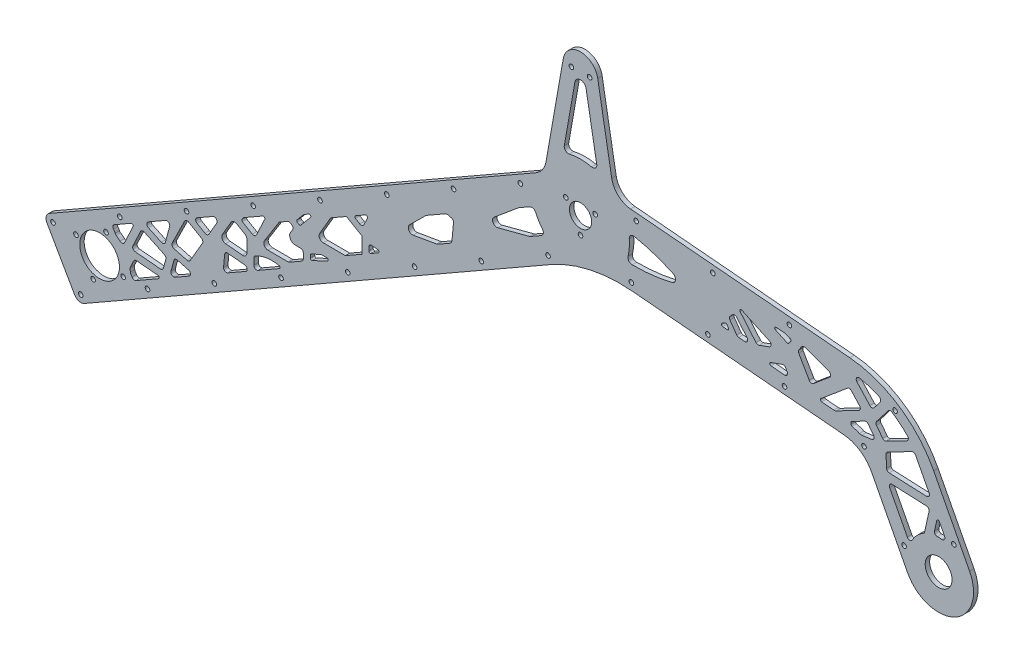
from build123d import *

# Parameters (mm, degrees)
SKETCH2_R              = 7.9375
SKETCH2_R_2            = 14.2
SKETCH2_R_3            = 1.65
SKETCH2_R_4            = 9.5885
BASE_DEPTH             = 3.175
SKETCH3_R              = 1.65
STRUT_HOLES_DEPTH      = 4.175
LIGHTENING_HOLES_DEPTH = 4.175
SKETCH7_R              = 1.65
CUT_EXTRUDE1_DEPTH     = 4.175


with BuildPart() as part:
    # Sketch2 → Base (new body)
    with BuildSketch(Plane.XY):
        with BuildLine():
            Line((-379.716809958, -188.506893436), (-32.006532147, 10.487277971))
            ThreePointArc((-32.006532147, 10.487277971), (-27.186230121, 14.879084252), (-24.685038782, 20.901319377))
            Line((-24.685038782, 20.901319377), (-12.310096913, 91.083102221))
            ThreePointArc((-12.310096913, 91.083102221), (0, 101.4125), (12.310096913, 91.083102221))
            Line((12.310096913, 91.083102221), (22.322003955, 34.302755831))
            ThreePointArc((22.322003955, 34.302755831), (26.960267136, 25.848318444), (35.786784109, 21.964558025))
            Line((35.786784109, 21.964558025), (192.586144941, 8.246391504))
            ThreePointArc((192.586144941, 8.246391504), (227.717231711, -4.10798993), (252.575276723, -31.83706486))
            Line((252.575276723, -31.83706486), (278.255270829, -81.167874559))
            ThreePointArc((278.255270829, -81.167874559), (267.623715331, -114.886860719), (233.904729171, -104.255305221))
            Line((233.904729171, -104.255305221), (208.224735064, -54.924495522))
            ThreePointArc((208.224735064, -54.924495522), (199.93872006, -45.681470545), (188.228357804, -41.563343401))
            Line((188.228357804, -41.563343401), (36.823729736, -28.317154839))
            ThreePointArc((36.823729736, -28.317154839), (6.649577682, -30.266109959), (-21.562664076, -41.144864173))
            Line((-21.562664076, -41.144864173), (-354.881400189, -231.902773674))
            ThreePointArc((-354.881400189, -231.902773674), (-358.677364619, -232.387866435), (-361.70452919, -230.046726627))
            Line((-361.70452919, -230.046726627), (-381.572857005, -195.330022437))
            ThreePointArc((-381.572857005, -195.330022437), (-382.057949767, -191.534058007), (-379.716809958, -188.506893436))
        make_face()
        Circle(SKETCH2_R, mode=Mode.SUBTRACT)
        with Locations((-343.92, -196.825)):
            Circle(SKETCH2_R_2, mode=Mode.SUBTRACT)
        with Locations((-6.5, 88.9125)):
            Circle(SKETCH2_R_3, mode=Mode.SUBTRACT)
        with Locations((6.5, 88.9125)):
            Circle(SKETCH2_R_3, mode=Mode.SUBTRACT)
        with Locations((256.08, -92.71158989)):
            Circle(SKETCH2_R_4, mode=Mode.SUBTRACT)
        with Locations((-360.806382749, -192.231517914)):
            Circle(SKETCH2_R_3, mode=Mode.SUBTRACT)
        with Locations((-339.326517914, -179.938617251)):
            Circle(SKETCH2_R_3, mode=Mode.SUBTRACT)
        with Locations((-327.033617251, -201.418482086)):
            Circle(SKETCH2_R_3, mode=Mode.SUBTRACT)
        with Locations((-348.513482086, -213.711382749)):
            Circle(SKETCH2_R_3, mode=Mode.SUBTRACT)
    extrude(amount=BASE_DEPTH)

    # Sketch3 → Strut Holes (cut, through all)
    with BuildSketch(Plane.XY.offset(3.175)):
        with Locations((-357.364941166, -227.56318565)):
            Circle(SKETCH3_R)
        with Locations((-309.629472905, -200.244234904)):
            Circle(SKETCH3_R)
        with Locations((-261.894004643, -172.925284158)):
            Circle(SKETCH3_R)
        with Locations((-214.158536382, -145.606333412)):
            Circle(SKETCH3_R)
        with Locations((-166.42306812, -118.287382666)):
            Circle(SKETCH3_R)
        with Locations((-118.687599859, -90.96843192)):
            Circle(SKETCH3_R)
        with Locations((-329.49780072, -165.527530714)):
            Circle(SKETCH3_R)
        with Locations((-377.233268981, -192.84648146)):
            Circle(SKETCH3_R)
        with Locations((-281.762332458, -138.208579968)):
            Circle(SKETCH3_R)
        with Locations((-234.026864197, -110.889629222)):
            Circle(SKETCH3_R)
        with Locations((-186.291395936, -83.570678476)):
            Circle(SKETCH3_R)
        with Locations((-138.555927674, -56.25172773)):
            Circle(SKETCH3_R)
        with Locations((36.307361546, -23.252879289)):
            Circle(SKETCH3_R)
        with Locations((91.098069941, -28.04644514)):
            Circle(SKETCH3_R)
        with Locations((145.888778336, -32.840010991)):
            Circle(SKETCH3_R)
        with Locations((149.375008046, 7.007776933)):
            Circle(SKETCH3_R)
        with Locations((94.584299651, 11.801342784)):
            Circle(SKETCH3_R)
        with Locations((39.793591256, 16.594908635)):
            Circle(SKETCH3_R)
        with Locations((-70.952131597, -63.649481174)):
            Circle(SKETCH3_R)
        with Locations((-23.216663336, -36.330530428)):
            Circle(SKETCH3_R)
        with Locations((-43.084991151, -1.613826238)):
            Circle(SKETCH3_R)
        with Locations((-90.820459413, -28.932776984)):
            Circle(SKETCH3_R)
        with Locations((202.716571226, -41.524122484)):
            Circle(SKETCH3_R)
        with Locations((224.939380546, -8.265337992)):
            Circle(SKETCH3_R)
        with Locations((231.413554138, -88.641399657)):
            Circle(SKETCH3_R)
        with Locations((266.893987465, -70.171455127)):
            Circle(SKETCH3_R)
    extrude(amount=-STRUT_HOLES_DEPTH, mode=Mode.SUBTRACT)

    # Sketch6 → Lightening Holes (cut, through all)
    with BuildSketch(Plane.XY.offset(3.175)):
        with BuildLine():
            Line((-317.937082153, -199.237754107), (-301.759255291, -189.979203363))
            ThreePointArc((-301.759255291, -189.979203363), (-301.27885272, -188.89855459), (-302.165025934, -188.115429161))
            Line((-302.165025934, -188.115429161), (-317.529091672, -186.71244549))
            ThreePointArc((-317.529091672, -186.71244549), (-318.704383169, -186.968323474), (-319.520360019, -187.852045956))
            Line((-319.520360019, -187.852045956), (-321.920665487, -192.94890269))
            ThreePointArc((-321.920665487, -192.94890269), (-322.086706026, -193.488507205), (-322.095332893, -194.053014132))
            ThreePointArc((-322.095332893, -194.053014132), (-321.995430567, -195.004765075), (-321.937013257, -195.959960211))
            ThreePointArc((-321.937013257, -195.959960211), (-321.816611469, -196.56901374), (-321.515239324, -197.111800643))
            ThreePointArc((-321.515239324, -197.111800643), (-321.089709213, -197.721191561), (-320.73119159, -198.372266273))
            ThreePointArc((-320.73119159, -198.372266273), (-319.522268091, -199.412366176), (-317.937082153, -199.237754107))
        make_face()
        with BuildLine():
            Line((-289.844978396, -183.160677107), (-279.93882887, -177.491399715))
            ThreePointArc((-279.93882887, -177.491399715), (-278.948378644, -175.502042811), (-280.407275879, -173.825692191))
            Line((-280.407275879, -173.825692191), (-288.292322007, -171.680779414))
            ThreePointArc((-288.292322007, -171.680779414), (-289.810707779, -171.874816518), (-290.747163702, -173.085682346))
            Line((-290.747163702, -173.085682346), (-292.868560549, -180.884280112))
            ThreePointArc((-292.868560549, -180.884280112), (-292.613471256, -182.502456625), (-291.234784363, -183.387209827))
            ThreePointArc((-291.234784363, -183.387209827), (-291.195764259, -183.393163574), (-291.156778347, -183.399337252))
            ThreePointArc((-291.156778347, -183.399337252), (-290.480404568, -183.392541824), (-289.844978396, -183.160677107))
        make_face()
        with BuildLine():
            Line((-225.068253149, -146.0890356), (-215.394271166, -140.552627413))
            ThreePointArc((-215.394271166, -140.552627413), (-214.903636001, -139.526112554), (-215.691072999, -138.704894803))
            ThreePointArc((-215.691072999, -138.704894803), (-224.321295756, -138.46558821), (-232.518295989, -141.176160044))
            ThreePointArc((-232.518295989, -141.176160044), (-233.286477009, -141.90836482), (-233.571916458, -142.930495063))
            Line((-233.571916458, -142.930495063), (-233.587977081, -147.160409637))
            Line((-233.587977081, -147.160409637), (-233.589300921, -147.509071621))
            ThreePointArc((-233.589300921, -147.509071621), (-232.59588453, -149.244906831), (-230.595898947, -149.252500605))
            Line((-230.595898947, -149.252500605), (-225.068253149, -146.0890356))
        make_face()
        with BuildLine():
            Line((-202.450189496, -105.529322903), (-201.311100417, -106.192755657))
            ThreePointArc((-201.311100417, -106.192755657), (-200.637908098, -106.314094916), (-200.044217491, -105.974326499))
            Line((-200.044217491, -105.974326499), (-193.10874934, -97.772404377))
            ThreePointArc((-193.10874934, -97.772404377), (-193.103868157, -96.486838424), (-194.369055865, -96.258795212))
            Line((-194.369055865, -96.258795212), (-197.510306407, -98.056529098))
            ThreePointArc((-197.510306407, -98.056529098), (-197.796638801, -98.255405281), (-198.044086675, -98.500981186))
            Line((-198.044086675, -98.500981186), (-202.710503229, -104.019510625))
            ThreePointArc((-202.710503229, -104.019510625), (-202.932364876, -104.835109908), (-202.450189496, -105.529322903))
        make_face()
        with BuildLine():
            Line((-333.444620565, -172.395023354), (-321.324736547, -165.45882839))
            ThreePointArc((-321.324736547, -165.45882839), (-320.149643655, -165.592039112), (-319.923331731, -166.752802359))
            Line((-319.923331731, -166.752802359), (-326.076688787, -179.818964042))
            ThreePointArc((-326.076688787, -179.818964042), (-327.489682534, -180.927174615), (-329.222241859, -180.455030372))
            ThreePointArc((-329.222241859, -180.455030372), (-330.587096563, -179.325466122), (-332.03841525, -178.309386485))
            ThreePointArc((-332.03841525, -178.309386485), (-332.502552417, -177.897052298), (-332.817881567, -177.362252973))
            ThreePointArc((-332.817881567, -177.362252973), (-333.319567754, -176.344657072), (-333.979051672, -175.421471605))
            ThreePointArc((-333.979051672, -175.421471605), (-334.420732076, -173.783065742), (-333.444620565, -172.395023354))
        make_face()
        with BuildLine():
            Line((-296.526078791, -175.281178461), (-298.296173769, -181.788333758))
            ThreePointArc((-298.296173769, -181.788333758), (-299.085121934, -182.906012266), (-300.407921189, -183.255077571))
            Line((-300.407921189, -183.255077571), (-318.426512518, -181.609693475))
            ThreePointArc((-318.426512518, -181.609693475), (-319.980472622, -180.611396672), (-320.054030653, -178.765867554))
            Line((-320.054030653, -178.765867554), (-314.587930437, -167.159040818))
            ThreePointArc((-314.587930437, -167.159040818), (-313.455436739, -166.129184627), (-311.926424469, -166.201760304))
            Line((-311.926424469, -166.201760304), (-297.603838378, -172.946815839))
            ThreePointArc((-297.603838378, -172.946815839), (-296.64013933, -173.917860945), (-296.526078791, -175.281178461))
        make_face()
        with BuildLine():
            Line((-296.725202345, -151.380544722), (-309.162121937, -158.49817876))
            ThreePointArc((-309.162121937, -158.49817876), (-310.167118822, -160.31366557), (-309.020818273, -162.043407211))
            Line((-309.020818273, -162.043407211), (-299.712508239, -166.427047688))
            ThreePointArc((-299.712508239, -166.427047688), (-298.022047377, -166.433466223), (-296.930523197, -165.142623828))
            Line((-296.930523197, -165.142623828), (-293.80191364, -153.641349312))
            ThreePointArc((-293.80191364, -153.641349312), (-294.508247327, -151.534307484), (-296.725202345, -151.380544722))
        make_face()
        with BuildLine():
            Line((-290.749203903, -165.830761417), (-281.418682259, -168.368876575))
            ThreePointArc((-281.418682259, -168.368876575), (-280.135367262, -168.289656018), (-279.165471442, -167.445573454))
            Line((-279.165471442, -167.445573454), (-270.334962051, -152.283921043))
            ThreePointArc((-270.334962051, -152.283921043), (-270.129400346, -150.767052513), (-271.056634293, -149.549110414))
            Line((-271.056634293, -149.549110414), (-280.339031078, -144.142820271))
            ThreePointArc((-280.339031078, -144.142820271), (-281.923077504, -143.956245777), (-283.139846515, -144.987500494))
            Line((-283.139846515, -144.987500494), (-292.018480766, -163.01732789))
            ThreePointArc((-292.018480766, -163.01732789), (-292.047293032, -164.72335957), (-290.749203903, -165.830761417))
        make_face()
        with BuildLine():
            Line((-274.174863713, -138.475013199), (-262.829621171, -131.982144615))
            ThreePointArc((-262.829621171, -131.982144615), (-260.416631803, -132.309146065), (-260.107963345, -134.724549018))
            Line((-260.107963345, -134.724549018), (-265.805400683, -144.506834582))
            ThreePointArc((-265.805400683, -144.506834582), (-267.023342782, -145.43406853), (-268.540211311, -145.228506825))
            Line((-268.540211311, -145.228506825), (-274.188016515, -141.939089844))
            ThreePointArc((-274.188016515, -141.939089844), (-275.181432906, -140.203254635), (-274.174863713, -138.475013199))
        make_face()
        with BuildLine():
            Line((-255.261313261, -159.742391016), (-254.488576255, -151.280152708))
            ThreePointArc((-254.488576255, -151.280152708), (-253.776611846, -149.925068788), (-252.314987955, -149.470314621))
            Line((-252.314987955, -149.470314621), (-240.229659184, -150.573897437))
            ThreePointArc((-240.229659184, -150.573897437), (-238.457312757, -152.140148294), (-239.418117899, -154.30144584))
            Line((-239.418117899, -154.30144584), (-252.276183677, -161.660101332))
            ThreePointArc((-252.276183677, -161.660101332), (-254.350596062, -161.606956723), (-255.261313261, -159.742391016))
        make_face()
        with BuildLine():
            Line((-249.949142761, -129.20392042), (-256.129617611, -139.815563221))
            ThreePointArc((-256.129617611, -139.815563221), (-256.203528398, -142.700549226), (-253.810068117, -144.312986801))
            Line((-253.810068117, -144.312986801), (-241.842841701, -145.405784992))
            ThreePointArc((-241.842841701, -145.405784992), (-239.551671104, -144.637726688), (-238.570050666, -142.429605863))
            Line((-238.570050666, -142.429605863), (-238.538476633, -134.113897012))
            ThreePointArc((-238.538476633, -134.113897012), (-238.934702194, -132.612381765), (-240.028601219, -131.510144198))
            Line((-240.028601219, -131.510144198), (-245.846926818, -128.121412056))
            ThreePointArc((-245.846926818, -128.121412056), (-248.122229612, -127.813069499), (-249.949142761, -129.20392042))
        make_face()
        with BuildLine():
            Line((-241.753564235, -124.719255848), (-234.63976684, -128.862501783))
            ThreePointArc((-234.63976684, -128.862501783), (-233.039032694, -129.043963991), (-231.823804406, -127.986373074))
            Line((-231.823804406, -127.986373074), (-225.796901327, -115.1887263))
            ThreePointArc((-225.796901327, -115.1887263), (-226.023213251, -114.027963054), (-227.198306143, -113.894752332))
            Line((-227.198306143, -113.894752332), (-240.486863137, -121.499777426))
            ThreePointArc((-240.486863137, -121.499777426), (-240.868014227, -121.782834524), (-241.171709307, -122.147754751))
            ThreePointArc((-241.171709307, -122.147754751), (-241.549582312, -122.675396768), (-241.974698217, -123.165774758))
            ThreePointArc((-241.974698217, -123.165774758), (-242.240299662, -123.996061899), (-241.753564235, -124.719255848))
        make_face()
        with BuildLine():
            Line((-215.700125094, -112.192821254), (-226.032975591, -128.589971196))
            ThreePointArc((-226.032975591, -128.589971196), (-226.124248281, -131.633833238), (-223.506276432, -133.189355733))
            Line((-223.506276432, -133.189355733), (-209.202252691, -133.243666885))
            ThreePointArc((-209.202252691, -133.243666885), (-208.68435958, -133.177484442), (-208.201242526, -132.979516511))
            Line((-208.201242526, -132.979516511), (-199.253531837, -127.858752507))
            ThreePointArc((-199.253531837, -127.858752507), (-198.518706793, -127.12948649), (-198.246962645, -126.130511071))
            Line((-198.246962645, -126.130511071), (-198.232362286, -122.28518887))
            ThreePointArc((-198.232362286, -122.28518887), (-198.812774892, -120.868761336), (-200.224754096, -120.277609512))
            Line((-200.224754096, -120.277609512), (-204.008629507, -120.263242462))
            ThreePointArc((-204.008629507, -120.263242462), (-207.499258639, -118.189212469), (-207.377561718, -114.130729746))
            Line((-207.377561718, -114.130729746), (-205.861080411, -111.724232972))
            ThreePointArc((-205.861080411, -111.724232972), (-205.610725726, -110.181490101), (-206.546571097, -108.929720762))
            Line((-206.546571097, -108.929720762), (-207.493132435, -108.378420775))
            ThreePointArc((-207.493132435, -108.378420775), (-208.492107854, -108.106676627), (-209.493118019, -108.370827001))
            Line((-209.493118019, -108.370827001), (-215.001481605, -111.523256819))
            ThreePointArc((-215.001481605, -111.523256819), (-215.391909437, -111.815147719), (-215.700125094, -112.192821254))
        make_face()
        with BuildLine():
            Line((-193.227653511, -121.054522852), (-193.234462366, -122.84778292))
            ThreePointArc((-193.234462366, -122.84778292), (-192.774967571, -123.692925108), (-191.815295507, -123.759485695))
            Line((-191.815295507, -123.759485695), (-180.993415111, -118.763096002))
            ThreePointArc((-180.993415111, -118.763096002), (-180.435478412, -117.642458946), (-181.408792291, -116.855197322))
            Line((-181.408792291, -116.855197322), (-185.032757855, -116.841437436))
            ThreePointArc((-185.032757855, -116.841437436), (-185.465813965, -116.887201486), (-185.878699763, -117.025611243))
            Line((-185.878699763, -117.025611243), (-192.646834787, -120.150413851))
            ThreePointArc((-192.646834787, -120.150413851), (-193.06900602, -120.517821741), (-193.227653511, -121.054522852))
        make_face()
        with BuildLine():
            Line((-168.149004332, -108.905485935), (-183.952737992, -108.845480513))
            ThreePointArc((-183.952737992, -108.845480513), (-186.545100145, -107.335626723), (-186.533709485, -104.335648348))
            Line((-186.533709485, -104.335648348), (-178.579876435, -90.679216235))
            Line((-178.579876435, -90.679216235), (-167.386832198, -84.273450557))
            Line((-167.386832198, -84.273450557), (-156.388373523, -90.679216235))
            Line((-156.388373523, -90.679216235), (-156.432116668, -102.199925297))
            Line((-156.432116668, -102.199925297), (-168.149004332, -108.905485935))
        make_face()
        with BuildLine():
            Line((-151.414615639, -97.600140871), (-151.405431829, -95.181384659))
            ThreePointArc((-151.405431829, -95.181384659), (-150.751018204, -93.709304109), (-149.223571139, -93.197265239))
            Line((-149.223571139, -93.197265239), (-145.032551994, -93.579971974))
            ThreePointArc((-145.032551994, -93.579971974), (-144.146378781, -94.363097402), (-144.626781352, -95.443746175))
            Line((-144.626781352, -95.443746175), (-149.917914652, -98.471855363))
            ThreePointArc((-149.917914652, -98.471855363), (-150.917907444, -98.468058476), (-151.414615639, -97.600140871))
        make_face()
        with BuildLine():
            Line((-160.872630183, -80.545380623), (-153.761861304, -76.475896195))
            ThreePointArc((-153.761861304, -76.475896195), (-152.586768412, -76.609106917), (-152.360456488, -77.769870163))
            Line((-152.360456488, -77.769870163), (-154.930028199, -83.226150228))
            ThreePointArc((-154.930028199, -83.226150228), (-156.145256487, -84.283741145), (-157.745990633, -84.102278936))
            Line((-157.745990633, -84.102278936), (-160.879206584, -82.277418946))
            ThreePointArc((-160.879206584, -82.277418946), (-161.375914779, -81.409501341), (-160.872630183, -80.545380623))
        make_face()
        with BuildLine():
            Line((-90.819864813, -49.698540482), (-91.896421351, -61.487904644))
            ThreePointArc((-91.896421351, -61.487904644), (-92.359955239, -62.836585977), (-93.393866555, -63.818844799))
            Line((-93.393866555, -63.818844799), (-101.994338017, -68.740884214))
            ThreePointArc((-101.994338017, -68.740884214), (-102.469113289, -68.960084777), (-102.974739436, -69.09351133))
            Line((-102.974739436, -69.09351133), (-119.629879497, -71.965101226))
            ThreePointArc((-119.629879497, -71.965101226), (-122.805875604, -70.383853511), (-122.252853304, -66.87936183))
            Line((-122.252853304, -66.87936183), (-110.681116507, -55.395166432))
            ThreePointArc((-110.681116507, -55.395166432), (-110.385100172, -55.137548838), (-110.057990454, -54.920773084))
            Line((-110.057990454, -54.920773084), (-96.724691463, -47.290142199))
            ThreePointArc((-96.724691463, -47.290142199), (-95.614849419, -46.918095089), (-94.447112805, -46.999086542))
            Line((-94.447112805, -46.999086542), (-92.286608626, -47.586793062))
            ThreePointArc((-92.286608626, -47.586793062), (-91.168930118, -48.375741228), (-90.819864813, -49.698540482))
        make_face()
        with BuildLine():
            Line((-28.096781534, -26.449402024), (-35.825401618, -30.87248195))
            ThreePointArc((-35.825401618, -30.87248195), (-36.178007781, -31.044706772), (-36.550077199, -31.169433846))
            Line((-36.550077199, -31.169433846), (-59.133973609, -37.128958431))
            ThreePointArc((-59.133973609, -37.128958431), (-62.565695554, -35.603385935), (-61.819045791, -31.92281518))
            Line((-61.819045791, -31.92281518), (-44.317223042, -17.349924163))
            ThreePointArc((-44.317223042, -17.349924163), (-44.108986088, -17.191390869), (-43.887724451, -17.051609889))
            Line((-43.887724451, -17.051609889), (-36.274597881, -12.694626761))
            ThreePointArc((-36.274597881, -12.694626761), (-33.845543285, -12.449097133), (-32.038330666, -14.090612767))
            ThreePointArc((-32.038330666, -14.090612767), (-29.904900702, -18.185073934), (-27.251097742, -21.963097956))
            ThreePointArc((-27.251097742, -21.963097956), (-26.638826778, -24.401372335), (-28.096781534, -26.449402024))
        make_face()
        with BuildLine():
            Line((-11.599665343, 37.524455033), (-3.986146646, 80.702865203))
            ThreePointArc((-3.986146646, 80.702865203), (0, 84.047639383), (3.986146646, 80.702865203))
            Line((3.986146646, 80.702865203), (11.599665343, 37.524455033))
            ThreePointArc((11.599665343, 37.524455033), (10.707449692, 34.824680589), (7.962722972, 34.082180723))
            ThreePointArc((7.962722972, 34.082180723), (0, 35), (-7.962722972, 34.082180723))
            ThreePointArc((-7.962722972, 34.082180723), (-10.707449692, 34.824680589), (-11.599665343, 37.524455033))
        make_face()
        with BuildLine():
            Line((246.075987756, -72.913561708), (249.254007124, -58.57844272))
            ThreePointArc((249.254007124, -58.57844272), (248.888121791, -56.928040634), (247.388653885, -56.147467049))
            Line((247.388653885, -56.147467049), (222.962162816, -55.080983417))
            ThreePointArc((222.962162816, -55.080983417), (221.188141149, -56.004480644), (221.100902375, -58.002577087))
            Line((221.100902375, -58.002577087), (233.735290203, -82.273010289))
            ThreePointArc((233.735290203, -82.273010289), (235.484637714, -83.349360854), (237.260008731, -82.316498325))
            ThreePointArc((237.260008731, -82.316498325), (240.657318696, -77.731906936), (245.140979083, -74.202461834))
            ThreePointArc((245.140979083, -74.202461834), (245.742284649, -73.655075389), (246.075987756, -72.913561708))
        make_face()
        with BuildLine():
            Line((253.133679234, -68.799730633), (254.751992566, -61.499990928))
            ThreePointArc((254.751992566, -61.499990928), (255.597762381, -60.72498568), (256.615299406, -61.254681929))
            Line((256.615299406, -61.254681929), (260.345615198, -68.420551892))
            ThreePointArc((260.345615198, -68.420551892), (260.223925452, -70.470902803), (258.359543018, -71.332775993))
            ThreePointArc((258.359543018, -71.332775993), (256.767087179, -71.222571503), (255.170843908, -71.230820928))
            ThreePointArc((255.170843908, -71.230820928), (253.553325039, -70.51716267), (253.133679234, -68.799730633))
        make_face()
        with BuildLine():
            Line((249.310771487, -47.22281435), (239.59747458, -28.563744597))
            ThreePointArc((239.59747458, -28.563744597), (238.424864512, -27.579807922), (236.899955687, -27.713220157))
            Line((236.899955687, -27.713220157), (219.565597936, -36.736915644))
            ThreePointArc((219.565597936, -36.736915644), (218.757044355, -37.510937311), (218.490998719, -38.598176086))
            Line((218.490998719, -38.598176086), (218.860832904, -47.068771554))
            ThreePointArc((218.860832904, -47.068771554), (219.444715785, -48.395746342), (220.771690573, -48.979629223))
            Line((220.771690573, -48.979629223), (247.449511046, -50.144408019))
            ThreePointArc((247.449511046, -50.144408019), (249.223532712, -49.220910793), (249.310771487, -47.22281435))
        make_face()
        with BuildLine():
            Line((233.413458883, -22.763883833), (218.618137266, -30.46584077))
            ThreePointArc((218.618137266, -30.46584077), (217.261760811, -30.644411118), (216.107933359, -29.909341962))
            Line((216.107933359, -29.909341962), (211.671799483, -24.128059737))
            ThreePointArc((211.671799483, -24.128059737), (211.258506163, -22.910536879), (211.671799483, -21.693014021))
            Line((211.671799483, -21.693014021), (220.007167815, -10.830150518))
            ThreePointArc((220.007167815, -10.830150518), (221.257760997, -10.076118732), (222.687548657, -10.3731953))
            ThreePointArc((222.687548657, -10.3731953), (228.553817552, -14.676513168), (233.918900039, -19.590528361))
            ThreePointArc((233.918900039, -19.590528361), (234.465065341, -21.304449895), (233.413458883, -22.763883833))
        make_face()
        with BuildLine():
            Line((209.61657846, -31.305721344), (205.746256457, -26.261819508))
            ThreePointArc((205.746256457, -26.261819508), (204.592429004, -25.526750352), (203.23605255, -25.7053207))
            Line((203.23605255, -25.7053207), (194.010059092, -30.508068903))
            ThreePointArc((194.010059092, -30.508068903), (193.616895834, -30.876306478), (193.471807705, -31.395079736))
            Line((193.471807705, -31.395079736), (193.471807705, -32.496691451))
            ThreePointArc((193.471807705, -32.496691451), (193.684204256, -33.112873898), (194.23116932, -33.467306291))
            ThreePointArc((194.23116932, -33.467306291), (196.89746606, -34.245224393), (199.491371204, -35.238175037))
            ThreePointArc((199.491371204, -35.238175037), (200.2654041, -35.454155852), (201.069000396, -35.456918226))
            Line((201.069000396, -35.456918226), (208.290924164, -34.506133925))
            ThreePointArc((208.290924164, -34.506133925), (209.877630844, -33.288611067), (209.61657846, -31.305721344))
        make_face()
        with BuildLine():
            Line((214.303083467, -8.407780179), (209.957683706, -14.070815403))
            ThreePointArc((209.957683706, -14.070815403), (208.4582158, -14.851388988), (206.896422352, -14.20447296))
            Line((206.896422352, -14.20447296), (197.688681904, -4.155987535))
            ThreePointArc((197.688681904, -4.155987535), (197.423723958, -1.817844179), (199.566737265, -0.845933158))
            ThreePointArc((199.566737265, -0.845933158), (206.676023639, -2.722269436), (213.536897173, -5.366320289))
            ThreePointArc((213.536897173, -5.366320289), (214.655785228, -6.701693203), (214.303083467, -8.407780179))
        make_face()
        with BuildLine():
            Line((193.681402215, -11.624307007), (199.545514004, -18.023862053))
            ThreePointArc((199.545514004, -18.023862053), (200.040574836, -19.722338824), (198.994456557, -21.149064135))
            Line((198.994456557, -21.149064135), (182.807531418, -29.575444012))
            ThreePointArc((182.807531418, -29.575444012), (182.007556544, -29.856767353), (181.16081835, -29.902995606))
            Line((181.16081835, -29.902995606), (172.48260155, -29.143750017))
            ThreePointArc((172.48260155, -29.143750017), (171.616040342, -28.448261118), (171.926969683, -27.381510875))
            Line((171.926969683, -27.381510875), (190.921272322, -11.443398536))
            ThreePointArc((190.921272322, -11.443398536), (192.3376538, -10.979769576), (193.681402215, -11.624307007))
        make_face()
        with BuildLine():
            Line((178.199205815, -11.022517891), (166.591800736, -20.762287211))
            ThreePointArc((166.591800736, -20.762287211), (164.958929162, -21.199813831), (163.574174709, -20.230198325))
            Line((163.574174709, -20.230198325), (156.047951006, -7.194396481))
            ThreePointArc((156.047951006, -7.194396481), (155.78190537, -6.107157706), (156.141697725, -5.047243608))
            Line((156.141697725, -5.047243608), (158.18845934, -2.124165087))
            ThreePointArc((158.18845934, -2.124165087), (159.22535183, -1.363884058), (160.510803716, -1.391932718))
            Line((160.510803716, -1.391932718), (177.597670882, -7.611043763))
            ThreePointArc((177.597670882, -7.611043763), (178.883246101, -9.143132649), (178.199205815, -11.022517891))
        make_face()
        with BuildLine():
            Line((146.644806866, -20.907673079), (147.746965574, -22.816667961))
            ThreePointArc((147.746965574, -22.816667961), (147.701697658, -24.891267177), (145.840603281, -25.809057357))
            Line((145.840603281, -25.809057357), (136.229987031, -24.968237386))
            ThreePointArc((136.229987031, -24.968237386), (135.325697913, -24.10256888), (135.975122631, -23.032350067))
            Line((135.975122631, -23.032350067), (144.228715771, -20.028287838))
            ThreePointArc((144.228715771, -20.028287838), (145.596796345, -20.028287838), (146.644806866, -20.907673079))
        make_face()
        with BuildLine():
            Line((134.974345297, -13.819003275), (127.671845659, -16.476895779))
            ThreePointArc((127.671845659, -16.476895779), (126.470167282, -16.52936219), (125.455716486, -15.883085757))
            Line((125.455716486, -15.883085757), (114.198527576, -2.46729043))
            ThreePointArc((114.198527576, -2.46729043), (114.171218678, -1.215741392), (115.387190281, -0.918195034))
            Line((115.387190281, -0.918195034), (135.135541534, -10.127002459))
            ThreePointArc((135.135541534, -10.127002459), (136.288401454, -12.026856808), (134.974345297, -13.819003275))
        make_face()
        with BuildLine():
            Line((139.430597275, -1.096040654), (147.83182135, -5.013595778))
            ThreePointArc((147.83182135, -5.013595778), (148.513258657, -5.073213817), (149.073591656, -4.680864427))
            Line((149.073591656, -4.680864427), (150.425898479, -2.749570135))
            ThreePointArc((150.425898479, -2.749570135), (150.560463385, -1.875287899), (149.948766578, -1.236301077))
            Line((149.948766578, -1.236301077), (146.098496258, 0.165082713))
            ThreePointArc((146.098496258, 0.165082713), (145.72175467, 0.274892872), (145.333903056, 0.334588945))
            Line((145.333903056, 0.334588945), (139.940371279, 0.806461832))
            ThreePointArc((139.940371279, 0.806461832), (138.88728971, 0.069086179), (139.430597275, -1.096040654))
        make_face()
        with BuildLine():
            Line((111.660494937, -7.221200049), (119.04545342, -16.022250853))
            ThreePointArc((119.04545342, -16.022250853), (119.2873862, -18.231323299), (117.339053048, -19.300215468))
            Line((117.339053048, -19.300215468), (113.116226003, -18.930765974))
            ThreePointArc((113.116226003, -18.930765974), (112.290537488, -18.670427385), (111.6522334, -18.08552945))
            Line((111.6522334, -18.08552945), (106.877510971, -11.266519132))
            ThreePointArc((106.877510971, -11.266519132), (106.523425664, -9.945054773), (107.101601497, -8.705152697))
            Line((107.101601497, -8.705152697), (108.714192488, -7.092561706))
            ThreePointArc((108.714192488, -7.092561706), (110.215644825, -6.508678825), (111.660494937, -7.221200049))
        make_face()
        with BuildLine():
            Line((104.703890017, -15.136053881), (105.75536165, -16.637710998))
            ThreePointArc((105.75536165, -16.637710998), (105.80223501, -17.711287434), (104.849053863, -18.207482132))
            Line((104.849053863, -18.207482132), (101.67727128, -17.929987113))
            ThreePointArc((101.67727128, -17.929987113), (100.788131016, -17.150232029), (101.264427023, -16.067767011))
            Line((101.264427023, -16.067767011), (103.384737973, -14.843604914))
            ThreePointArc((103.384737973, -14.843604914), (104.101177587, -14.73333431), (104.703890017, -15.136053881))
        make_face()
        with BuildLine():
            ThreePointArc((34.863622447, 3.086718303), (34.900341082, -2.63935454), (34.002891304, -8.294780463))
            ThreePointArc((34.002891304, -8.294780463), (34.552114447, -10.851108963), (36.89804352, -12.005699039))
            ThreePointArc((36.89804352, -12.005699039), (51.290024205, -11.233136631), (65.485577957, -8.740705208))
            ThreePointArc((65.485577957, -8.740705208), (67.910545504, -5.973310403), (66.09771963, -2.77134164))
            ThreePointArc((66.09771963, -2.77134164), (52.541526947, 2.603547383), (38.433463256, 6.29439159))
            ThreePointArc((38.433463256, 6.29439159), (35.846829531, 5.582787002), (34.863622447, 3.086718303))
        make_face()
    extrude(amount=-LIGHTENING_HOLES_DEPTH, mode=Mode.SUBTRACT)

    # Sketch7 → Cut-Extrude1 (cut, through all)
    with BuildSketch(Plane.XY.offset(3.175)):
        with Locations((-10.5, 6.062177826)):
            Circle(SKETCH7_R)
        with Locations((10.5, 6.062177826)):
            Circle(SKETCH7_R)
        with Locations((0, -12.124355653)):
            Circle(SKETCH7_R)
    extrude(amount=-CUT_EXTRUDE1_DEPTH, mode=Mode.SUBTRACT)


solid = part.part
